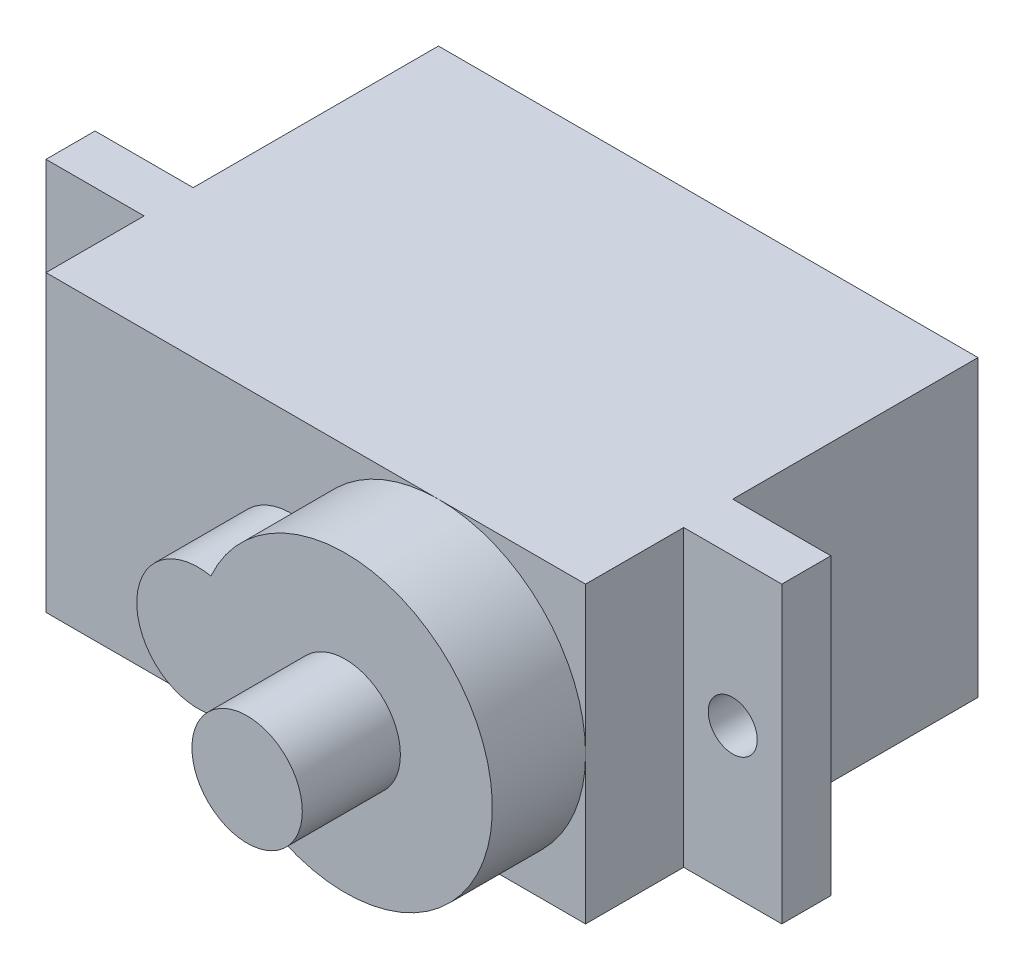
from build123d import *

# Parameters (mm, degrees)
SKETCH1_W      = 22
SKETCH1_H      = 12
EXTRUDE1_DEPTH = 10
SKETCH2_W      = 30
SKETCH2_H      = 12
EXTRUDE2_DEPTH = 2
SKETCH3_W      = 22
SKETCH3_H      = 12
EXTRUDE3_DEPTH = 4
SKETCH4_R      = 1
EXTRUDE4_DEPTH = 13
EXTRUDE5_DEPTH = 3.8
SKETCH6_R      = 2.25
EXTRUDE6_DEPTH = 4


with BuildPart() as part:
    # Sketch1 → Extrude1 (new body)
    with BuildSketch(Plane.XY):
        Rectangle(SKETCH1_W, SKETCH1_H)
    extrude(amount=EXTRUDE1_DEPTH)

    # Sketch2 → Extrude2 (add)
    with BuildSketch(Plane.XY.offset(10)):
        Rectangle(SKETCH2_W, SKETCH2_H)
    extrude(amount=EXTRUDE2_DEPTH)

    # Sketch3 → Extrude3 (add)
    with BuildSketch(Plane.XY.offset(12)):
        Rectangle(SKETCH3_W, SKETCH3_H)
    extrude(amount=EXTRUDE3_DEPTH)

    # Sketch4 → Extrude4 (cut, through all)
    with BuildSketch(Plane.XY.offset(12)):
        with Locations((-13, 0)):
            Circle(SKETCH4_R)
        with Locations((13, 0)):
            Circle(SKETCH4_R)
    extrude(amount=-EXTRUDE4_DEPTH, mode=Mode.SUBTRACT)

    # Sketch5 → Extrude5 (add)
    with BuildSketch(Plane.XY.offset(16)):
        with BuildLine():
            ThreePointArc((-0.479166667, -2.445144707), (11, 0), (-0.479166667, 2.445144707))
            ThreePointArc((-0.479166667, 2.445144707), (-3.5, 0), (-0.479166667, -2.445144707))
        make_face()
    extrude(amount=EXTRUDE5_DEPTH)

    # Sketch6 → Extrude6 (add)
    with BuildSketch(Plane.XY.offset(19.8)):
        with Locations((5, 0)):
            Circle(SKETCH6_R)
    extrude(amount=EXTRUDE6_DEPTH)


solid = part.part
